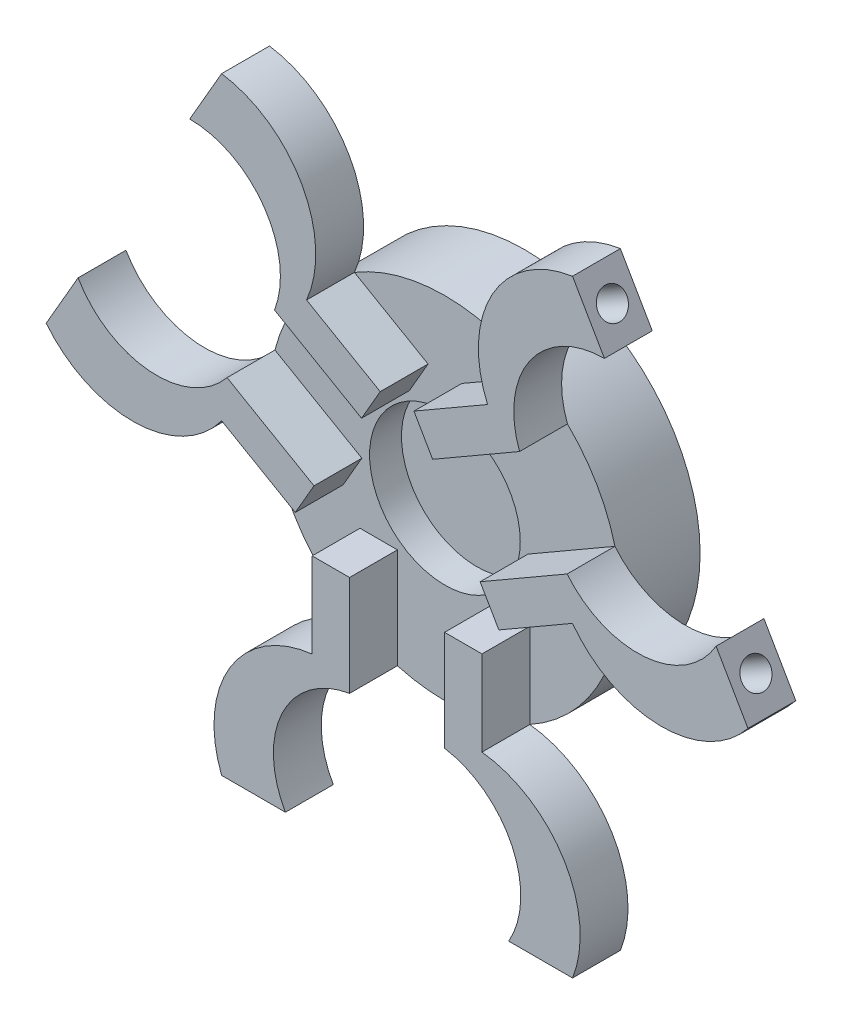
from build123d import *

# Parameters (mm, degrees)
SKETCH_1_R          = 11
EXTRUDE_1_DEPTH     = 2
EXTRUDE_2_DEPTH     = 3
SKETCH_4_R          = 0.9
CUT_EXTRUDE_1_DEPTH = 4
SKETCH_5_R          = 0.9
CUT_EXTRUDE_2_DEPTH = 4
SKETCH_6_R          = 0.9
CUT_EXTRUDE_3_DEPTH = 4
SKETCH_8_R          = 11
EXTRUDE_3_DEPTH     = 3
SKETCH_9_R          = 4.723532035
CUT_EXTRUDE_4_DEPTH = 2


with BuildPart() as part:
    # 草图1 → 凸台-拉伸1 (new body)
    with BuildSketch(Plane.XY):
        Circle(SKETCH_1_R)
    extrude(amount=EXTRUDE_1_DEPTH)

    # 草图2 → 凸台-拉伸2 (add)
    with BuildSketch(Plane.XY.offset(2)):
        with BuildLine():
            ThreePointArc((-5.674338907, 9.423474835), (-6.722663515, 8.706652357), (-7.681381188, 7.873778194))
            Line((-7.681381188, 7.873778194), (-2.2295398, 4.726156102))
            Line((-2.2295398, 4.726156102), (-1.056740901, 6.757503383))
            Line((-1.056740901, 6.757503383), (-5.674338907, 9.423474835))
        make_face()
        with BuildLine():
            Line((-11, 19.052558883), (-13, 15.588457268))
            ThreePointArc((-13, 15.588457268), (-8.322973179, 13.122163256), (-7.681381188, 7.873778194))
            ThreePointArc((-7.681381188, 7.873778194), (-6.722663515, 8.706652357), (-5.674338907, 9.423474835))
            ThreePointArc((-5.674338907, 9.423474835), (-5.965261919, 15.549873274), (-11, 19.052558883))
        make_face()
        with BuildLine():
            Line((-20, 3.464101615), (-22, 0))
            ThreePointArc((-22, 0), (-16.44921624, -2.608868275), (-10.998138053, 0.202384226))
            ThreePointArc((-10.998138053, 0.202384226), (-10.901513881, 1.468671206), (-10.659582534, 2.715382148))
            ThreePointArc((-10.659582534, 2.715382148), (-15.525613322, 0.64682458), (-20, 3.464101615))
        make_face()
        with BuildLine():
            ThreePointArc((-10.659582534, 2.715382148), (-10.901513881, 1.468671206), (-10.998138053, 0.202384226))
            Line((-10.998138053, 0.202384226), (-6.380540046, -2.463587226))
            Line((-6.380540046, -2.463587226), (-5.207741146, -0.432239945))
            Line((-5.207741146, -0.432239945), (-10.659582534, 2.715382148))
        make_face()
        with BuildLine():
            ThreePointArc((-5.323799145, -9.625859061), (-10.483954321, -12.941004999), (-11, -19.052558883))
            Line((-11, -19.052558883), (-7, -19.052558883))
            ThreePointArc((-7, -19.052558883), (-7.202640143, -13.768987836), (-2.978201346, -10.589160342))
            ThreePointArc((-2.978201346, -10.589160342), (-4.178850366, -10.175323563), (-5.323799145, -9.625859061))
        make_face()
        with BuildLine():
            Line((-5.323799145, -4.293916157), (-5.323799145, -9.625859061))
            ThreePointArc((-5.323799145, -9.625859061), (-4.178850366, -10.175323563), (-2.978201346, -10.589160342))
            Line((-2.978201346, -10.589160342), (-2.978201346, -4.293916157))
            Line((-2.978201346, -4.293916157), (-5.323799145, -4.293916157))
        make_face()
        with BuildLine():
            Line((2.978201346, -4.293916157), (2.978201346, -10.589160342))
            ThreePointArc((2.978201346, -10.589160342), (4.178850366, -10.175323563), (5.323799145, -9.625859061))
            Line((5.323799145, -9.625859061), (5.323799145, -4.293916157))
            Line((5.323799145, -4.293916157), (2.978201346, -4.293916157))
        make_face()
        with BuildLine():
            ThreePointArc((2.978201346, -10.589160342), (7.202640143, -13.768987836), (7, -19.052558883))
            Line((7, -19.052558883), (11, -19.052558883))
            ThreePointArc((11, -19.052558883), (10.483954321, -12.941004999), (5.323799145, -9.625859061))
            ThreePointArc((5.323799145, -9.625859061), (4.178850366, -10.175323563), (2.978201346, -10.589160342))
        make_face()
        with BuildLine():
            ThreePointArc((10.998138053, 0.202384226), (16.44921624, -2.608868275), (22, 0))
            Line((22, 0), (20, 3.464101615))
            ThreePointArc((20, 3.464101615), (15.525613322, 0.64682458), (10.659582534, 2.715382148))
            ThreePointArc((10.659582534, 2.715382148), (10.901513881, 1.468671206), (10.998138053, 0.202384226))
        make_face()
        with BuildLine():
            Line((6.380540046, -2.463587226), (10.998138053, 0.202384226))
            ThreePointArc((10.998138053, 0.202384226), (10.901513881, 1.468671206), (10.659582534, 2.715382148))
            Line((10.659582534, 2.715382148), (5.207741146, -0.432239945))
            Line((5.207741146, -0.432239945), (6.380540046, -2.463587226))
        make_face()
        with BuildLine():
            ThreePointArc((7.681381188, 7.873778194), (6.722663515, 8.706652357), (5.674338907, 9.423474835))
            Line((5.674338907, 9.423474835), (1.056740901, 6.757503383))
            Line((1.056740901, 6.757503383), (2.2295398, 4.726156102))
            Line((2.2295398, 4.726156102), (7.681381188, 7.873778194))
        make_face()
        with BuildLine():
            Line((13, 15.588457268), (11, 19.052558883))
            ThreePointArc((11, 19.052558883), (5.965261919, 15.549873274), (5.674338907, 9.423474835))
            ThreePointArc((5.674338907, 9.423474835), (6.722663515, 8.706652357), (7.681381188, 7.873778194))
            ThreePointArc((7.681381188, 7.873778194), (8.322973179, 13.122163256), (13, 15.588457268))
        make_face()
    extrude(amount=EXTRUDE_2_DEPTH)

    # 草图4 → 切除-拉伸1 (cut)
    with BuildSketch(Plane(origin=(-16.5, 9.526279442, 0), x_dir=(0, 0, 1), z_dir=(-0.866025404, 0.5, 0))):
        with Locations((3.5, 9)):
            Circle(SKETCH_4_R)
        with Locations((3.5, -9)):
            Circle(SKETCH_4_R)
    extrude(amount=-CUT_EXTRUDE_1_DEPTH, mode=Mode.SUBTRACT)

    # 草图5 → 切除-拉伸2 (cut)
    with BuildSketch(Plane(origin=(16.5, 9.526279442, 0), x_dir=(0, 0, -1), z_dir=(0.866025404, 0.5, 0))):
        with Locations((-3.5, -9)):
            Circle(SKETCH_5_R)
        with Locations((-3.5, 9)):
            Circle(SKETCH_5_R)
    extrude(amount=-CUT_EXTRUDE_2_DEPTH, mode=Mode.SUBTRACT)

    # 草图6 → 切除-拉伸3 (cut)
    with BuildSketch(Plane.XZ.offset(19.052558883)):
        with Locations((-9, 3.5)):
            Circle(SKETCH_6_R)
        with Locations((9, 3.5)):
            Circle(SKETCH_6_R)
    extrude(amount=-CUT_EXTRUDE_3_DEPTH, mode=Mode.SUBTRACT)

    # 草图8 → 凸台-拉伸3 (add)
    with BuildSketch(Plane(origin=(0, 0, 0), x_dir=(-1, 0, 0), z_dir=(0, 0, -1))):
        Circle(SKETCH_8_R)
    extrude(amount=EXTRUDE_3_DEPTH)

    # 草图9 → 切除-拉伸4 (cut)
    with BuildSketch(Plane.XY.offset(2)):
        Circle(SKETCH_9_R)
    extrude(amount=-CUT_EXTRUDE_4_DEPTH, mode=Mode.SUBTRACT)


solid = part.part
